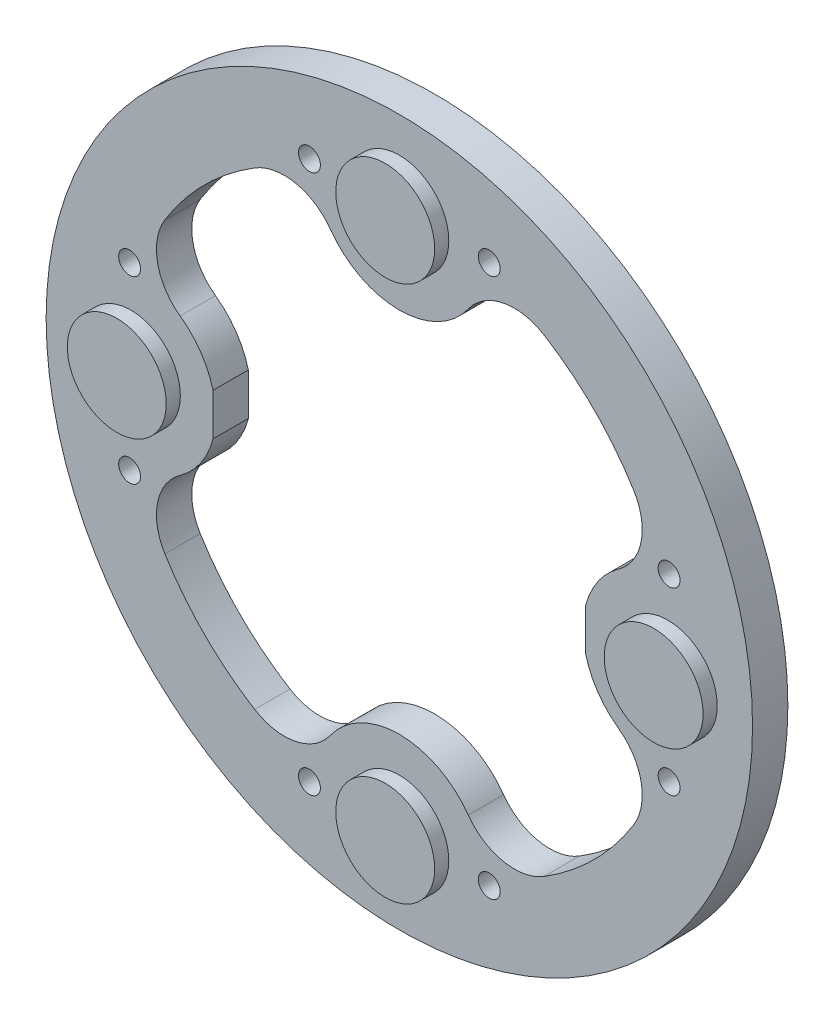
from build123d import *

# Parameters (mm, degrees)
SKETCH1_R           = 50
BOSS_EXTRUDE1_DEPTH = 5
SKETCH2_R           = 7
BOSS_EXTRUDE2_DEPTH = 2
CUT_EXTRUDE1_REACH  = 7
SKETCH3_R           = 1.55


with BuildPart() as part:
    # Sketch1 → Boss-Extrude1 (new body)
    with BuildSketch(Plane.XY):
        Circle(SKETCH1_R)
        with BuildLine():
            ThreePointArc((-31.028947368, -9.767518887), (-28.10136985, -6.783592054), (-26.375, -2.976470225))
            Line((-26.375, -2.976470225), (-26.375, 2.976470225))
            ThreePointArc((-26.375, 2.976470225), (-28.10136985, 6.783592054), (-31.028947368, 9.767518887))
            ThreePointArc((-31.028947368, 9.767518887), (-34.223647748, 14.6974406), (-33.189728353, 20.480281537))
            ThreePointArc((-33.189728353, 20.480281537), (-27.577164466, 27.577164466), (-20.480281537, 33.189728353))
            ThreePointArc((-20.480281537, 33.189728353), (-14.6974406, 34.223647748), (-9.767518887, 31.028947368))
            ThreePointArc((-9.767518887, 31.028947368), (0, 26), (9.767518887, 31.028947368))
            ThreePointArc((9.767518887, 31.028947368), (14.6974406, 34.223647748), (20.480281537, 33.189728353))
            ThreePointArc((20.480281537, 33.189728353), (27.577164466, 27.577164466), (33.189728353, 20.480281537))
            ThreePointArc((33.189728353, 20.480281537), (34.223647748, 14.6974406), (31.028947368, 9.767518887))
            ThreePointArc((31.028947368, 9.767518887), (28.10136985, 6.783592054), (26.375, 2.976470225))
            Line((26.375, 2.976470225), (26.375, -2.976470225))
            ThreePointArc((26.375, -2.976470225), (28.10136985, -6.783592054), (31.028947368, -9.767518887))
            ThreePointArc((31.028947368, -9.767518887), (34.223647748, -14.6974406), (33.189728353, -20.480281537))
            ThreePointArc((33.189728353, -20.480281537), (27.577164466, -27.577164466), (20.480281537, -33.189728353))
            ThreePointArc((20.480281537, -33.189728353), (14.6974406, -34.223647748), (9.767518887, -31.028947368))
            ThreePointArc((9.767518887, -31.028947368), (0, -26), (-9.767518887, -31.028947368))
            ThreePointArc((-9.767518887, -31.028947368), (-14.6974406, -34.223647748), (-20.480281537, -33.189728353))
            ThreePointArc((-20.480281537, -33.189728353), (-27.577164466, -27.577164466), (-33.189728353, -20.480281537))
            ThreePointArc((-33.189728353, -20.480281537), (-34.223647748, -14.6974406), (-31.028947368, -9.767518887))
        make_face(mode=Mode.SUBTRACT)
    extrude(amount=BOSS_EXTRUDE1_DEPTH)

    # Sketch2 → Boss-Extrude2 (add)
    with BuildSketch(Plane.XY.offset(5)):
        with Locations((-38, 0)):
            Circle(SKETCH2_R)
        with Locations((0, 38)):
            Circle(SKETCH2_R)
        with Locations((38, 0)):
            Circle(SKETCH2_R)
        with Locations((0, -38)):
            Circle(SKETCH2_R)
    extrude(amount=BOSS_EXTRUDE2_DEPTH)

    # Sketch3 → Cut-Extrude1 (cut, up to next)
    with BuildSketch(Plane.XY.offset(5), mode=Mode.PRIVATE) as cut_extrude1_sk1:
        with Locations((-12.727922061, 38.183766184)):
            Circle(SKETCH3_R)
    cut_extrude1_tool1 = extrude(cut_extrude1_sk1.sketch, amount=-CUT_EXTRUDE1_REACH, mode=Mode.PRIVATE) & part.part
    add(cut_extrude1_tool1.solids().sort_by_distance((-12.727922, 38.183766, 5))[0], mode=Mode.SUBTRACT)
    # Sketch3 → Cut-Extrude1 (cut, up to next)
    with BuildSketch(Plane.XY.offset(5), mode=Mode.PRIVATE) as cut_extrude1_sk2:
        with Locations((38.183766184, 12.727922061)):
            Circle(SKETCH3_R)
    cut_extrude1_tool2 = extrude(cut_extrude1_sk2.sketch, amount=-CUT_EXTRUDE1_REACH, mode=Mode.PRIVATE) & part.part
    add(cut_extrude1_tool2.solids().sort_by_distance((38.183766, 12.727922, 5))[0], mode=Mode.SUBTRACT)
    # Sketch3 → Cut-Extrude1 (cut, up to next)
    with BuildSketch(Plane.XY.offset(5), mode=Mode.PRIVATE) as cut_extrude1_sk3:
        with Locations((12.727922061, -38.183766184)):
            Circle(SKETCH3_R)
    cut_extrude1_tool3 = extrude(cut_extrude1_sk3.sketch, amount=-CUT_EXTRUDE1_REACH, mode=Mode.PRIVATE) & part.part
    add(cut_extrude1_tool3.solids().sort_by_distance((12.727922, -38.183766, 5))[0], mode=Mode.SUBTRACT)
    # Sketch3 → Cut-Extrude1 (cut, up to next)
    with BuildSketch(Plane.XY.offset(5), mode=Mode.PRIVATE) as cut_extrude1_sk4:
        with Locations((-38.183766184, -12.727922061)):
            Circle(SKETCH3_R)
    cut_extrude1_tool4 = extrude(cut_extrude1_sk4.sketch, amount=-CUT_EXTRUDE1_REACH, mode=Mode.PRIVATE) & part.part
    add(cut_extrude1_tool4.solids().sort_by_distance((-38.183766, -12.727922, 5))[0], mode=Mode.SUBTRACT)
    # Sketch3 → Cut-Extrude1 (cut, up to next)
    with BuildSketch(Plane.XY.offset(5), mode=Mode.PRIVATE) as cut_extrude1_sk5:
        with Locations((-38.183766184, 12.727922061)):
            Circle(SKETCH3_R)
    cut_extrude1_tool5 = extrude(cut_extrude1_sk5.sketch, amount=-CUT_EXTRUDE1_REACH, mode=Mode.PRIVATE) & part.part
    add(cut_extrude1_tool5.solids().sort_by_distance((-38.183766, 12.727922, 5))[0], mode=Mode.SUBTRACT)
    # Sketch3 → Cut-Extrude1 (cut, up to next)
    with BuildSketch(Plane.XY.offset(5), mode=Mode.PRIVATE) as cut_extrude1_sk6:
        with Locations((12.727922061, 38.183766184)):
            Circle(SKETCH3_R)
    cut_extrude1_tool6 = extrude(cut_extrude1_sk6.sketch, amount=-CUT_EXTRUDE1_REACH, mode=Mode.PRIVATE) & part.part
    add(cut_extrude1_tool6.solids().sort_by_distance((12.727922, 38.183766, 5))[0], mode=Mode.SUBTRACT)
    # Sketch3 → Cut-Extrude1 (cut, up to next)
    with BuildSketch(Plane.XY.offset(5), mode=Mode.PRIVATE) as cut_extrude1_sk7:
        with Locations((38.183766184, -12.727922061)):
            Circle(SKETCH3_R)
    cut_extrude1_tool7 = extrude(cut_extrude1_sk7.sketch, amount=-CUT_EXTRUDE1_REACH, mode=Mode.PRIVATE) & part.part
    add(cut_extrude1_tool7.solids().sort_by_distance((38.183766, -12.727922, 5))[0], mode=Mode.SUBTRACT)
    # Sketch3 → Cut-Extrude1 (cut, up to next)
    with BuildSketch(Plane.XY.offset(5), mode=Mode.PRIVATE) as cut_extrude1_sk8:
        with Locations((-12.727922061, -38.183766184)):
            Circle(SKETCH3_R)
    cut_extrude1_tool8 = extrude(cut_extrude1_sk8.sketch, amount=-CUT_EXTRUDE1_REACH, mode=Mode.PRIVATE) & part.part
    add(cut_extrude1_tool8.solids().sort_by_distance((-12.727922, -38.183766, 5))[0], mode=Mode.SUBTRACT)


solid = part.part
